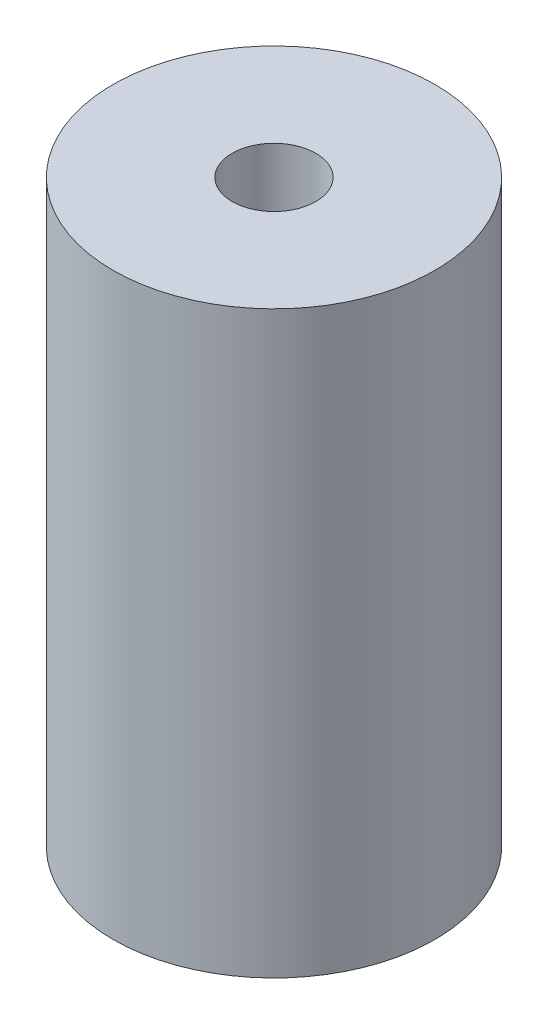
from build123d import *

# Parameters (mm, degrees)
SKETCH1_R           = 250
BOSS_EXTRUDE1_DEPTH = 900
CUT_EXTRUDE1_START  = -100
SKETCH5_R           = 200
CUT_EXTRUDE1_DEPTH  = 700
SKETCH6_R           = 65
CUT_EXTRUDE2_DEPTH  = 1356


with BuildPart() as part:
    # Sketch1 → Boss-Extrude1 (new body)
    with BuildSketch(Plane(origin=(0, 0, 0), x_dir=(1, 0, 0), z_dir=(0, 1, 0))):
        Circle(SKETCH1_R)
    extrude(amount=BOSS_EXTRUDE1_DEPTH)

    # Sketch5 → Cut-Extrude1 (cut)
    with BuildSketch(Plane(origin=(0, 0, 0), x_dir=(-1, 0, 0), z_dir=(0, -1, 0)).offset(CUT_EXTRUDE1_START)):
        Circle(SKETCH5_R)
    extrude(amount=-CUT_EXTRUDE1_DEPTH, mode=Mode.SUBTRACT)

    # Sketch6 → Cut-Extrude2 (cut)
    with BuildSketch(Plane(origin=(0, 900, 0), x_dir=(1, 0, 0), z_dir=(0, 1, 0))):
        Circle(SKETCH6_R)
    extrude(amount=-CUT_EXTRUDE2_DEPTH, mode=Mode.SUBTRACT)


solid = part.part
